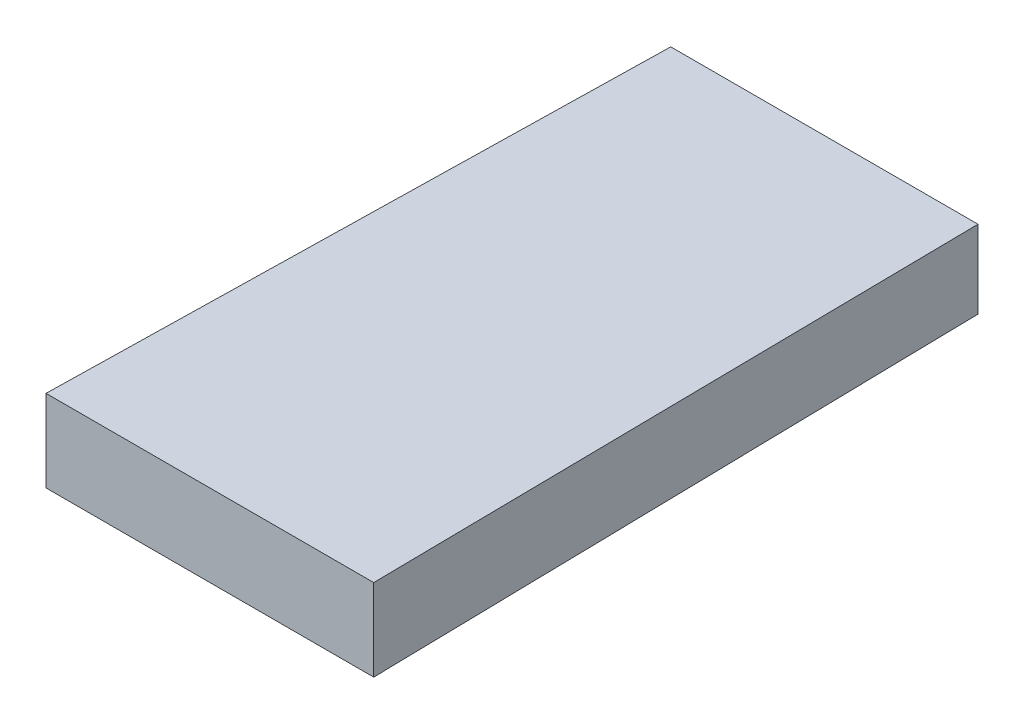
from build123d import *

# Parameters (mm, degrees)
SKETCH3_W = 150
SKETCH3_H = 38
SKETCH4_W = 160
SKETCH4_H = 40


with BuildPart() as part:
    # Sketch3 → Loft1 section 0
    with BuildSketch(Plane.XY):
        Rectangle(SKETCH3_W, SKETCH3_H)
    # Sketch4 → Loft1 section 1
    with BuildSketch(Plane.XY.offset(300)):
        Rectangle(SKETCH4_W, SKETCH4_H)
    loft()


solid = part.part
